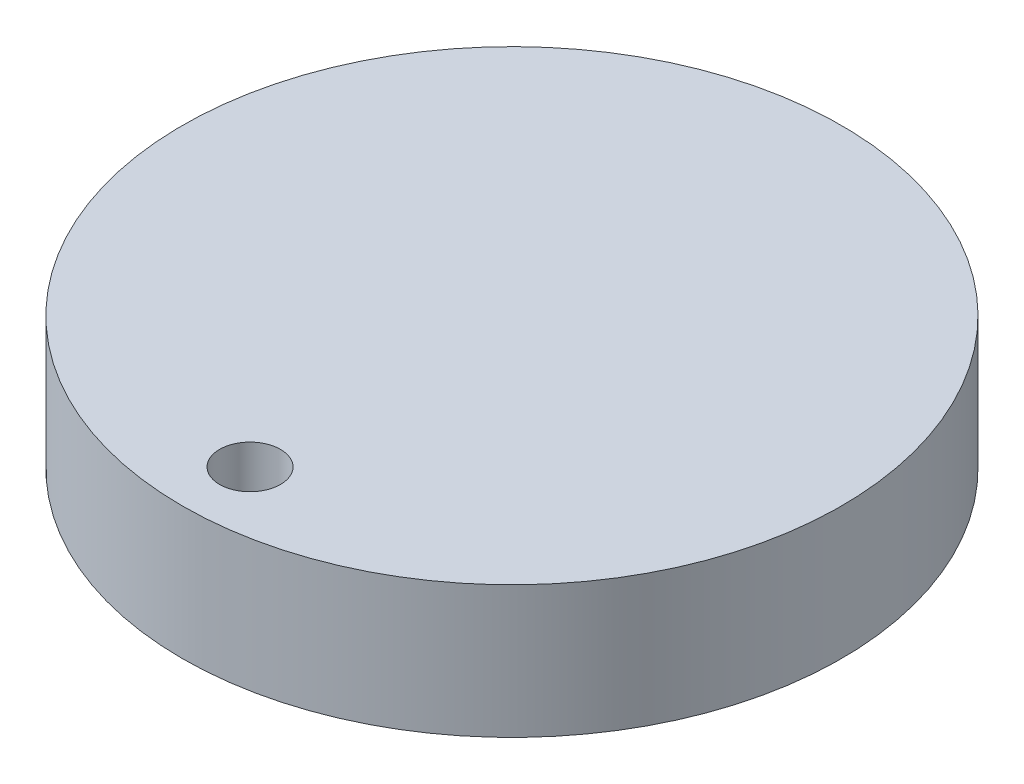
from build123d import *

# Parameters (mm, degrees)
SKETCH1_R           = 12.662852008
SKETCH1_R_2         = 1.169736377
BOSS_EXTRUDE3_DEPTH = 5.08


with BuildPart() as part:
    # Sketch1 → Boss-Extrude3 (new body)
    with BuildSketch(Plane(origin=(0, 0, 0), x_dir=(1, 0, 0), z_dir=(0, 1, 0))):
        Circle(SKETCH1_R)
        with Locations((0, -10.062541764)):
            Circle(SKETCH1_R_2, mode=Mode.SUBTRACT)
    extrude(amount=BOSS_EXTRUDE3_DEPTH)


solid = part.part
